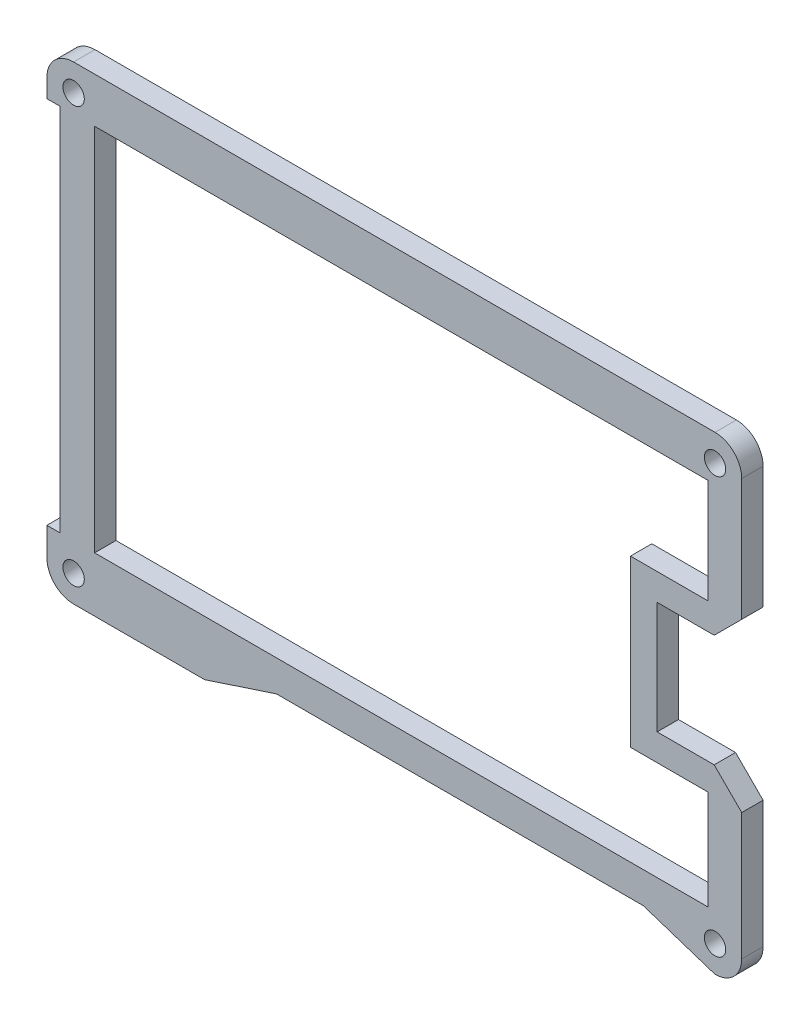
from build123d import *

# Parameters (mm, degrees)
BOSS_EXTRUDE1_DEPTH = 3.048
SKETCH2_R           = 1.355900406
CUT_EXTRUDE1_DEPTH  = 4.048
SKETCH3_R           = 1.524
CUT_EXTRUDE2_DEPTH  = 4.048
CUT_EXTRUDE3_DEPTH  = 4.048
BOSS_EXTRUDE2_DEPTH = 3.048
SKETCH5_W           = 11.049
SKETCH5_H           = 14.8839
SKETCH5_W_2         = 76.4276
SKETCH5_H_2         = 52.6961
SKETCH5_H_3         = 14.1902
CUT_EXTRUDE4_DEPTH  = 4.048


with BuildPart() as part:
    # Sketch1 → Boss-Extrude1 (new body)
    with BuildSketch(Plane.XY):
        with BuildLine():
            Line((-309.8086, 128.8851), (-305.87795, 128.8851))
            Line((-305.87795, 128.8851), (-301.9473, 132.81575))
            Line((-301.9473, 132.81575), (-301.9473, 150.9704))
            ThreePointArc((-301.9473, 150.9704), (-303.063223164, 153.664476836), (-305.7573, 154.7804))
            Line((-305.7573, 154.7804), (-397.247125, 154.7804))
            ThreePointArc((-397.247125, 154.7804), (-399.946077222, 153.659592612), (-401.0571, 150.956597849))
            Line((-401.0571, 150.956597849), (-401.0571, 148.341))
            Line((-401.0571, 148.341), (-399.1521, 148.341))
            Line((-399.1521, 148.341), (-399.1521, 95.6449))
            Line((-399.1521, 95.6449), (-401.0571, 95.6449))
            Line((-401.0571, 95.6449), (-401.0571, 91.659304166))
            ThreePointArc((-401.0571, 91.659304166), (-399.951018769, 88.947400452), (-397.2472, 87.8217))
            Line((-397.2472, 87.8217), (-378.5565, 87.8217))
            Line((-378.5565, 87.8217), (-368.3165, 91.1883))
            Line((-368.3165, 91.1883), (-315.9973, 91.1883))
            Line((-315.9973, 91.1883), (-305.7573, 87.8217))
            ThreePointArc((-305.7573, 87.8217), (-303.063223164, 88.937623164), (-301.9473, 91.6317))
            Line((-301.9473, 91.6317), (-301.9473, 111.74645))
            Line((-301.9473, 111.74645), (-305.87795, 115.6771))
            Line((-305.87795, 115.6771), (-309.8086, 115.6771))
            Line((-309.8086, 115.6771), (-314.0123, 115.6771))
            Line((-314.0123, 115.6771), (-314.0123, 128.8851))
            Line((-314.0123, 128.8851), (-309.8086, 128.8851))
        make_face()
        Polygon((-395.3675, 92.9525), (-395.3675, 149.2432), (-309.8086, 149.2432), (-309.8086, 132.81575), (-318.2033, 132.81575), (-318.2033, 111.74645), (-309.8086, 111.74645), (-309.8086, 92.9525), align=None, mode=Mode.SUBTRACT)
    extrude(amount=BOSS_EXTRUDE1_DEPTH)

    # Sketch2 → Cut-Extrude1 (cut, through all)
    with BuildSketch(Plane(origin=(0, 0, 0), x_dir=(-1, 0, 0), z_dir=(0, 0, -1))):
        with Locations((305.7573, 150.9704)):
            Circle(SKETCH2_R)
        with Locations((397.247125, 150.9704)):
            Circle(SKETCH2_R)
        with Locations((397.2472, 91.6317)):
            Circle(SKETCH2_R)
        with Locations((305.7573, 91.6317)):
            Circle(SKETCH2_R)
    extrude(amount=-CUT_EXTRUDE1_DEPTH, mode=Mode.SUBTRACT)

    # Sketch3 → Cut-Extrude2 (cut, through all)
    with BuildSketch(Plane(origin=(0, 0, 0), x_dir=(-1, 0, 0), z_dir=(0, 0, -1))):
        with Locations((305.7573, 150.9704)):
            Circle(SKETCH3_R)
        with Locations((397.247125, 150.9704)):
            Circle(SKETCH3_R)
        with Locations((397.2472, 91.6317)):
            Circle(SKETCH3_R)
        with Locations((305.7573, 91.6317)):
            Circle(SKETCH3_R)
    extrude(amount=-CUT_EXTRUDE2_DEPTH, mode=Mode.SUBTRACT)

    # Sketch4 → Cut-Extrude3 (cut, through all)
    with BuildSketch(Plane.XY.offset(3.048)):
        Polygon((-301.9473, 133.57775), (-305.87795, 129.6471), (-314.0123, 129.6471), (-314.0123, 113.6451), (-305.87795, 113.6451), (-301.9473, 109.71445), align=None)
    extrude(amount=-CUT_EXTRUDE3_DEPTH, mode=Mode.SUBTRACT)

    # Sketch4_4 → Boss-Extrude2 (add)
    with BuildSketch(Plane.XY.offset(3.048)):
        Polygon((-318.2033, 111.74645), (-318.2033, 132.81575), (-309.8086, 132.81575), (-309.8086, 149.2432), (-395.3675, 149.2432), (-395.3675, 92.9525), (-309.8086, 92.9525), (-309.8086, 111.74645), align=None)
    extrude(amount=-BOSS_EXTRUDE2_DEPTH)

    # Sketch5 → Cut-Extrude4 (cut, through all)
    with BuildSketch(Plane.XY.offset(3.048)):
        with Locations((-312.2978, 140.89905)):
            Rectangle(SKETCH5_W, SKETCH5_H)
        with Locations((-356.0361, 121.99295)):
            Rectangle(SKETCH5_W_2, SKETCH5_H_2)
        with Locations((-312.2978, 102.74)):
            Rectangle(SKETCH5_W, SKETCH5_H_3)
    extrude(amount=-CUT_EXTRUDE4_DEPTH, mode=Mode.SUBTRACT)


solid = part.part
